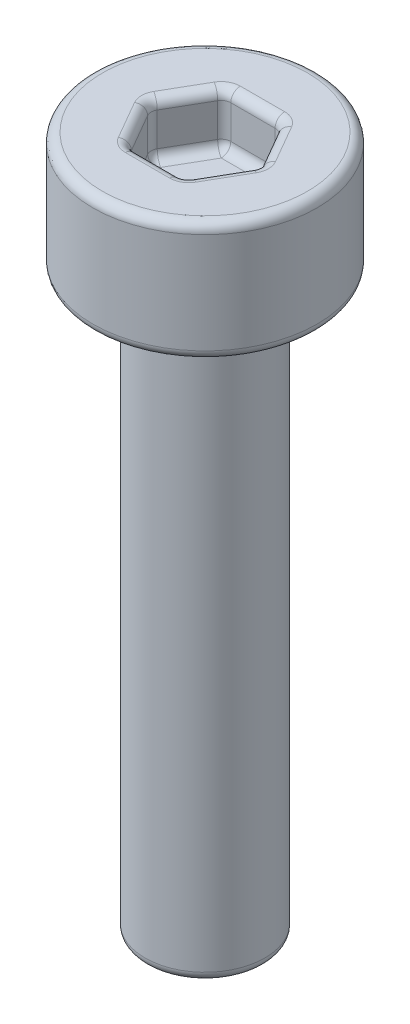
from build123d import *

# Parameters (mm, degrees)
SKETCH_1_R          = 1.25
EXTRUDE_1_DEPTH     = 12
SKETCH_2_R          = 2.34
EXTRUDE_2_DEPTH     = 2.5
CUT_EXTRUDE_1_DEPTH = 1.1
FILLET_1_R          = 0.2


with BuildPart() as part:
    # 草图1 → 凸台-拉伸1 (new body)
    with BuildSketch(Plane(origin=(0, 0, 0), x_dir=(1, 0, 0), z_dir=(0, 1, 0))):
        Circle(SKETCH_1_R)
    extrude(amount=-EXTRUDE_1_DEPTH)

    # 草图2 → 凸台-拉伸2 (add)
    with BuildSketch(Plane(origin=(0, 0, 0), x_dir=(1, 0, 0), z_dir=(0, 1, 0))):
        Circle(SKETCH_2_R)
    extrude(amount=EXTRUDE_2_DEPTH)

    # 草图3 → 切除-拉伸1 (cut)
    with BuildSketch(Plane(origin=(0, 2.5, 0), x_dir=(1, 0, 0), z_dir=(0, 1, 0))):
        Polygon((1.154700538, 0), (0.577350269, 1), (-0.577350269, 1), (-1.154700538, 0), (-0.577350269, -1), (0.577350269, -1), align=None)
    extrude(amount=-CUT_EXTRUDE_1_DEPTH, mode=Mode.SUBTRACT)

    # 圆角1
    fillet_1_edges = [part.edges().sort_by_distance(p)[0] for p in [
        (0.866025404, 1.4, 0.5),
        (1.154700538, 1.95, 0),
        (0, 1.4, 1),
        (0.577350269, 1.95, 1),
        (-0.866025404, 1.4, 0.5),
        (-0.577350269, 1.95, 1),
        (-0.866025404, 1.4, -0.5),
        (-1.154700538, 1.95, 0),
        (0, 1.4, -1),
        (-0.577350269, 1.95, -1),
        (0.866025404, 1.4, -0.5),
        (0.577350269, 1.95, -1),
        (0.866025404, 2.5, 0.5),
        (0.866025404, 2.5, -0.5),
        (0, 2.5, -1),
        (-0.866025404, 2.5, -0.5),
        (-0.866025404, 2.5, 0.5),
        (0, 2.5, 1),
        (-1.25, -12, 0),
        (-2.34, 0, 0),
        (-2.34, 2.5, 0),
    ]]
    fillet(fillet_1_edges, radius=FILLET_1_R)


solid = part.part
